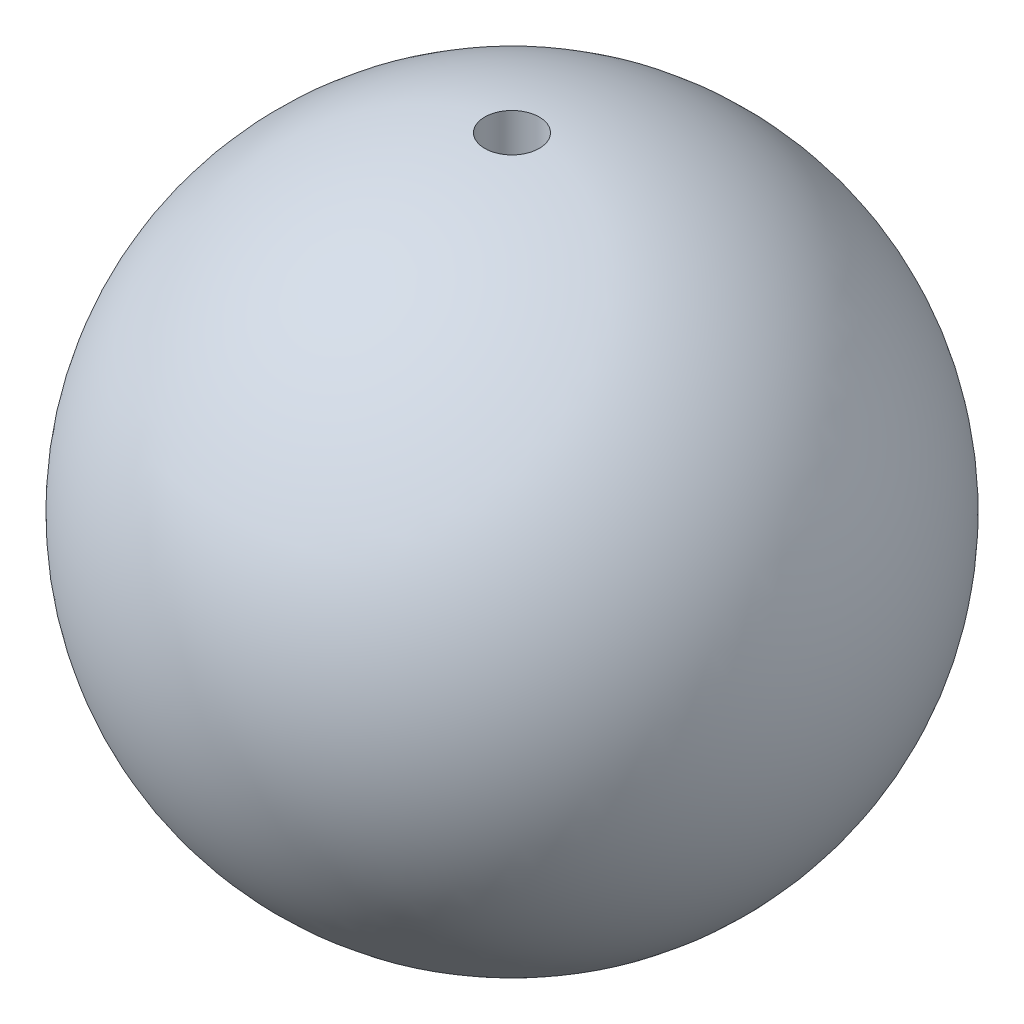
from build123d import *

# Parameters (mm, degrees)
SKETCH2_R  = 1.5748
HOLE_DEPTH = 20.05


with BuildPart() as part:
    # Sketch1 → Revolve1 (revolve)
    with BuildSketch(Plane.XY):
        with BuildLine():
            Line((0, 19.05), (0, -19.05))
            ThreePointArc((0, -19.05), (19.05, 0), (0, 19.05))
        make_face()
    revolve(axis=Axis((0, 19.05, 0), (0, -1, 0)))

    # Sketch2 → Hole (cut, through all)
    with BuildSketch(Plane(origin=(0, 0, 0), x_dir=(1, 0, 0), z_dir=(0, 1, 0))):
        Circle(SKETCH2_R)
    extrude(amount=HOLE_DEPTH, mode=Mode.SUBTRACT)


solid = part.part
